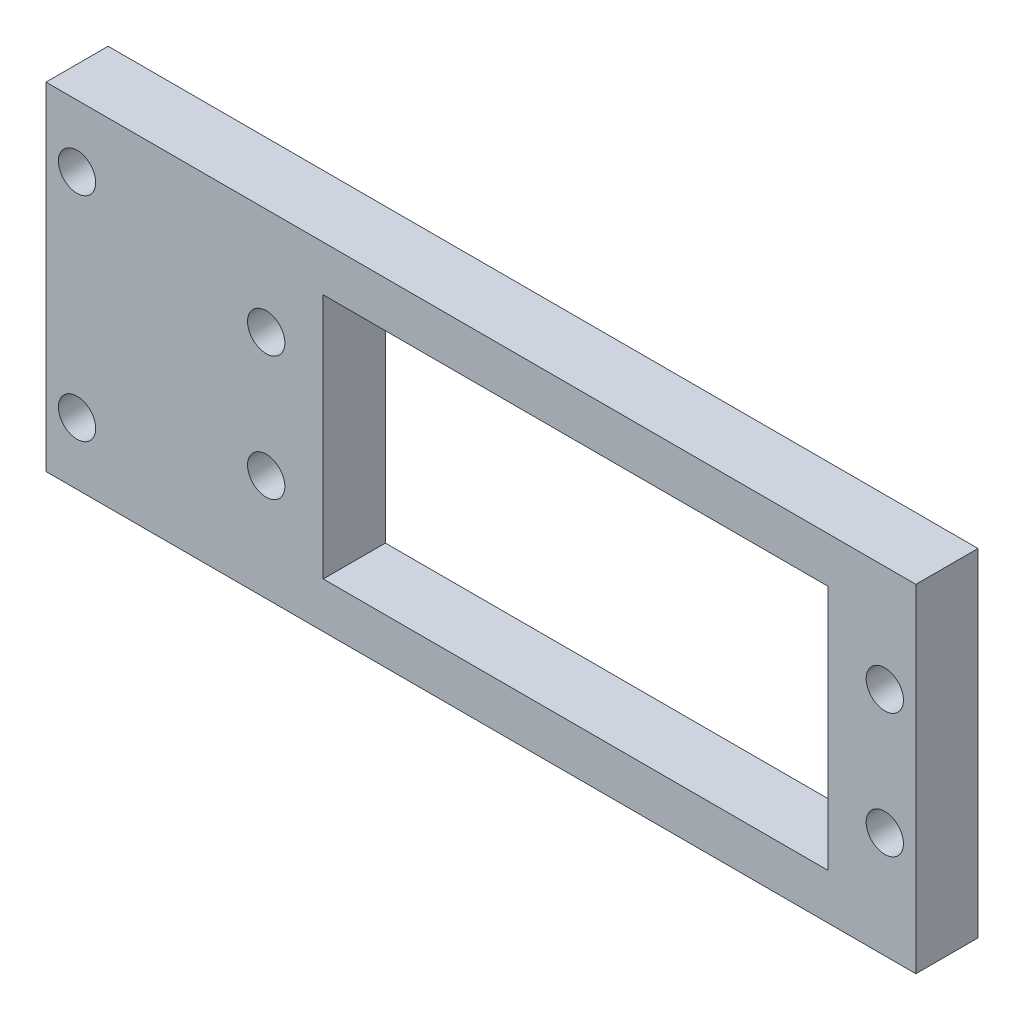
from build123d import *

# Parameters (mm, degrees)
ESBO_O1_W                = 70
ESBO_O1_H                = 27.14
RESSALTO_EXTRUS_O1_DEPTH = 5
ESBO_O2_R                = 1.5
CORTE_EXTRUS_O1_DEPTH    = 5
ESBO_O4_W                = 40.6
ESBO_O4_H                = 19.8
CORTE_EXTRUS_O2_DEPTH    = 6
ESBO_O5_R                = 1.5
CORTE_EXTRUS_O3_DEPTH    = 6


with BuildPart() as part:
    # Esboço1 → Ressalto-extrusão1 (new body)
    with BuildSketch(Plane.XY):
        with Locations((8.249487122, 6.106616915)):
            Rectangle(ESBO_O1_W, ESBO_O1_H)
    extrude(amount=RESSALTO_EXTRUS_O1_DEPTH)

    # Esboço2 → Corte-extrusão1 (cut)
    with BuildSketch(Plane.XY.offset(5)):
        with Locations((-24.250512878, 14.676616915)):
            Circle(ESBO_O2_R)
        with Locations((-24.250512878, -2.463383085)):
            Circle(ESBO_O2_R)
        with Locations((40.749487122, 11.106616915)):
            Circle(ESBO_O2_R)
        with Locations((40.749487122, 1.106616915)):
            Circle(ESBO_O2_R)
    extrude(amount=-CORTE_EXTRUS_O1_DEPTH, mode=Mode.SUBTRACT)

    # Esboço4 → Corte-extrusão2 (cut, through all)
    with BuildSketch(Plane(origin=(0, 0, 0), x_dir=(-1, 0, 0), z_dir=(0, 0, -1))):
        with Locations((-15.859487122, 6.106616915)):
            Rectangle(ESBO_O4_W, ESBO_O4_H)
    extrude(amount=-CORTE_EXTRUS_O2_DEPTH, mode=Mode.SUBTRACT)

    # Esboço5 → Corte-extrusão3 (cut, through all)
    with BuildSketch(Plane(origin=(0, 0, 0), x_dir=(-1, 0, 0), z_dir=(0, 0, -1))):
        with Locations((9.030512878, 1.106616915)):
            Circle(ESBO_O5_R)
        with Locations((9.030512878, 11.106616915)):
            Circle(ESBO_O5_R)
    extrude(amount=-CORTE_EXTRUS_O3_DEPTH, mode=Mode.SUBTRACT)


solid = part.part
